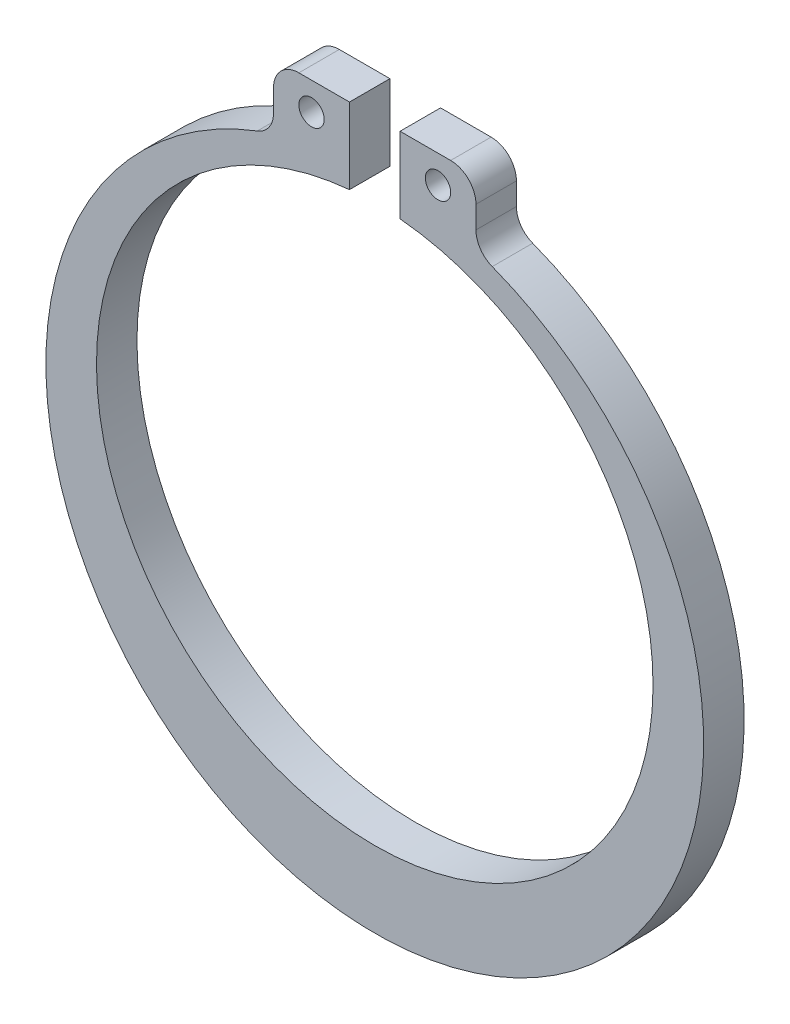
from build123d import *

# Parameters (mm, degrees)
SKETCH_1_R             = 0.25
EXTRUDE_1_DEPTH        = 0.4
FILLET_1_R             = 0.5
FILLET_1_OF_MIRROR_1_R = 0.5


with BuildPart() as part:
    # Эскиз1 → Бобышка-Вытянуть1 (new body, symmetric)
    with BuildSketch(Plane.XY):
        with BuildLine():
            Line((2, 6.977225575), (0.5, 6.977225575))
            Line((0.5, 6.977225575), (0.5, 5.980740698))
            ThreePointArc((0.5, 5.980740698), (1.258735944, 5.876957254), (2, 5.684658438))
            Line((2, 5.684658438), (2, 6.977225575))
        make_face()
        with Locations((1.25, 6.427950493)):
            Circle(SKETCH_1_R, mode=Mode.SUBTRACT)
        with BuildLine():
            ThreePointArc((2, 5.684658438), (1.258735944, 5.876957254), (0.5, 5.980740698))
            Line((0.5, 5.980740698), (0.5, 5.477225575))
            ThreePointArc((0.5, 5.477225575), (5.494303444, -0.250259203), (0, -5.5))
            Line((0, -5.5), (0, -7))
            ThreePointArc((0, -7), (6.420680643, -1.51235373), (2, 5.684658438))
        make_face()
    extrude_1 = extrude(amount=EXTRUDE_1_DEPTH, both=True)

    # Скругление1
    fillet_1_edges = [part.edges().sort_by_distance(p)[0] for p in [
        (2, 6.977225575, 0),
        (2, 5.684658438, 0),
    ]]
    fillet(fillet_1_edges, radius=FILLET_1_R)

    # Зеркальное отражение1: Бобышка-Вытянуть1 across plane
    add(extrude_1.mirror(Plane(origin=(0, 0, 0.4), x_dir=(0, 0, 1), z_dir=(1, 0, 0))))

    # Скругление1 of Зеркальное отражение1
    fillet_1_of_mirror_1_edges = [part.edges().sort_by_distance(p)[0] for p in [
        (-2, 6.977225575, 0),
        (-2, 5.684658438, 0),
    ]]
    fillet(fillet_1_of_mirror_1_edges, radius=FILLET_1_OF_MIRROR_1_R)


solid = part.part
